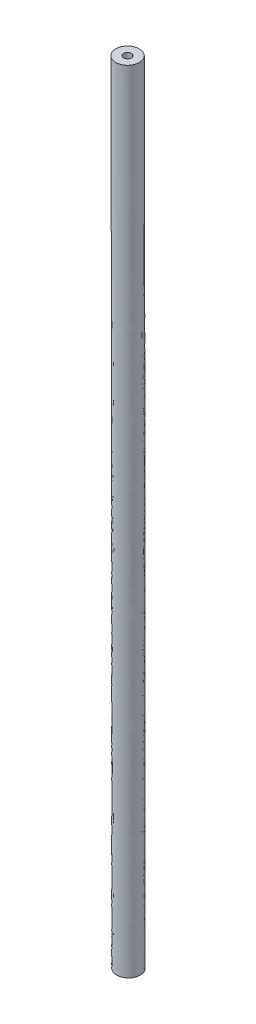
from build123d import *

# Parameters (mm, degrees)
SKETCH1_R                 = 1.5
SKETCH1_R_2               = 0.5
F_2_0MM_DOWEL_HOLE1_D     = 2
F_2_0MM_DOWEL_HOLE1_DEPTH = 7.5
F_2_0MM_DOWEL_HOLE1_TIP   = 0.600860619


with BuildPart() as part:
    # Sweep1: sweep along a path in Sketch2
    with BuildLine(Plane.XY) as sweep1_path:
        Line((0, 0), (0, 25))
        ThreePointArc((0, 25), (-0.015624988, 50.000019531), (-0.062499927, 75))
        Line((-0.062499927, 75), (-0.124999951, 100))
    # Sketch1 → Sweep1 (sweep)
    with BuildSketch(Plane(origin=(0, 0, 0), x_dir=(1, 0, 0), z_dir=(0, 1, 0))):
        Circle(SKETCH1_R)
        Circle(SKETCH1_R_2, mode=Mode.SUBTRACT)
    sweep(path=sweep1_path.line)

    # Ø2.0mm Dowel Hole1
    with Locations(Plane(origin=(0, 0, 0), x_dir=(-1, 0, 0), z_dir=(0, -1, 0))):
        with Locations((0, 0)):
            Hole(F_2_0MM_DOWEL_HOLE1_D / 2, depth=F_2_0MM_DOWEL_HOLE1_DEPTH)
            with Locations((0, 0, -(F_2_0MM_DOWEL_HOLE1_DEPTH + F_2_0MM_DOWEL_HOLE1_TIP / 2))):  # 118° drill point
                Cone(0, F_2_0MM_DOWEL_HOLE1_D / 2, F_2_0MM_DOWEL_HOLE1_TIP, mode=Mode.SUBTRACT)


solid = part.part
